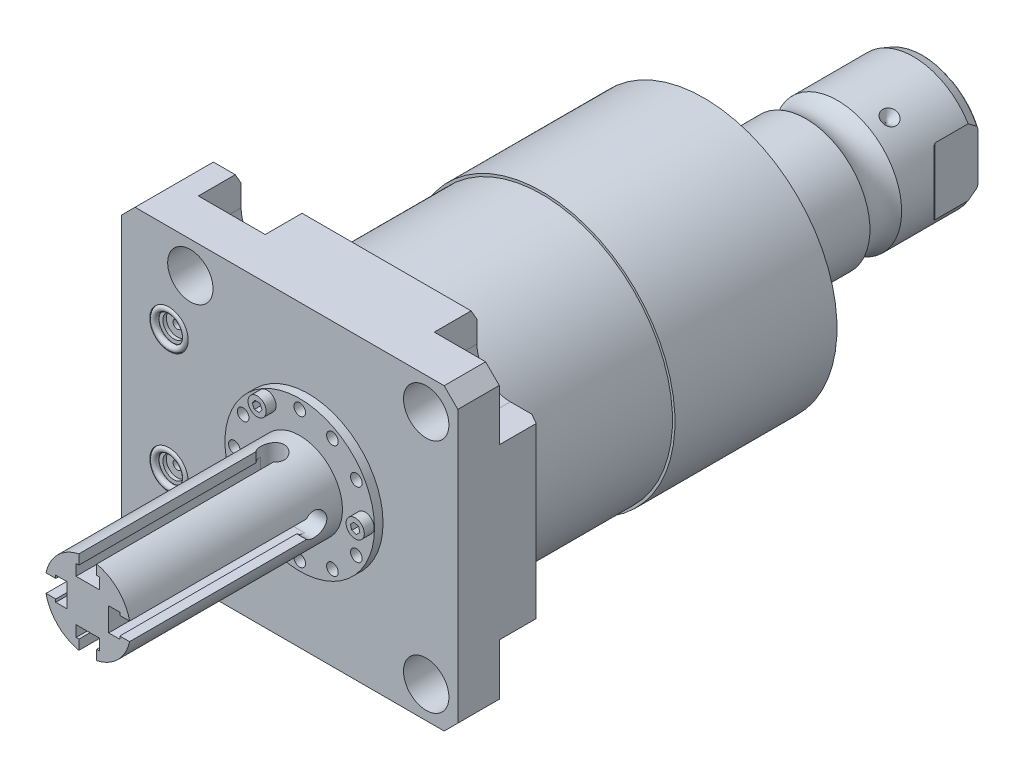
from build123d import *

# Parameters (mm, degrees)
SKETCH1_W                   = 99.9998
SKETCH1_H                   = 88.9
EXTRUDE1_DEPTH              = 25.019
SKETCH2_R                   = 6.7437
CUT_EXTRUDE1_DEPTH          = 27.5209
LPATTERN1_COUNT             = 2
LPATTERN1_PITCH             = 70.104
LPATTERN1_COUNT_DIR2        = 2
LPATTERN1_PITCH_DIR2        = 70.104
CUT_EXTRUDE2_DEPTH          = 12.7
SKETCH6_R                   = 5.7023
CUT_EXTRUDE3_DEPTH          = 1.4478
SKETCH7_R                   = 3.2512
CUT_EXTRUDE4_DEPTH          = 1.016
SKETCH8_R                   = 1.2446
CUT_EXTRUDE5_DEPTH          = 11.9888
SKETCH9_R                   = 0.9271
LPATTERN3_COUNT             = 2
LPATTERN3_PITCH             = 36.2204
CHAMFER1_SIZE               = 4.064
CHAMFER2_SIZE               = 3.0226
CHAMFER2_SIZE2              = 1.745098924
SKETCH14_R                  = 39.5224
EXTRUDE2_DEPTH              = 96.393
SKETCH15_OUTSIDE_W          = 138.19
SKETCH15_OUTSIDE_H          = 127.09
SKETCH15_OUTSIDE_R          = 38.7858
CUT_EXTRUDE9_DEPTH          = 44.45
CIRPATTERN1_COUNT           = 3
FILLET1_R                   = 0.635
CUT_EXTRUDE12_DEPTH         = 45.45
CUT_EXTRUDE12_DEPTH_BACK    = 45.45
SKETCH28_R                  = 1.7272
CUT_EXTRUDE13_DEPTH         = 2.54
SKETCH29_R                  = 2.7051
EXTRUDE3_DEPTH              = 2.9464
CUT_EXTRUDE14_DEPTH         = 2.032
CUT_EXTRUDE15_DEPTH         = 6.477
SKETCH32_W                  = 6.985
SKETCH32_H                  = 54.864
CUT_EXTRUDE16_DEPTH         = 3.302
CIRPATTERN2_COUNT           = 2
CIRPATTERN2_ANGLE           = 90
CIRPATTERN2_COPY_1_DEPTH    = 6.477
CIRPATTERN2_COPY_2_SKETCH_W = 6.985
CIRPATTERN2_COPY_2_SKETCH_H = 54.864
CIRPATTERN2_COPY_2_DEPTH    = 3.302


with BuildPart() as part:
    # Sketch1 → Extrude1 (new body)
    with BuildSketch(Plane.XY):
        with Locations((-5.5499, 0)):
            Rectangle(SKETCH1_W, SKETCH1_H)
    extrude(amount=EXTRUDE1_DEPTH)

    # Sketch2 → Cut-Extrude1 (cut)
    with BuildSketch(Plane(origin=(0, 0, 0), x_dir=(-1, 0, 0), z_dir=(0, 0, -1))):
        with Locations((-35.052, -35.052)):
            Circle(SKETCH2_R)
    cut_extrude1 = extrude(amount=-CUT_EXTRUDE1_DEPTH, mode=Mode.SUBTRACT)

    # LPattern1: Cut-Extrude1 2 × 2
    with Locations(*[(-j * LPATTERN1_PITCH_DIR2, i * LPATTERN1_PITCH, 0) for i in range(LPATTERN1_COUNT) for j in range(LPATTERN1_COUNT_DIR2) if (i, j) != (0, 0)]):
        add(cut_extrude1, mode=Mode.SUBTRACT)

    # Sketch3 → Cut-Extrude2 (cut)
    with BuildSketch(Plane(origin=(0, 0, 0), x_dir=(-1, 0, 0), z_dir=(0, 0, -1))):
        with BuildLine():
            Line((-35.052, -25.1206), (-44.45, -25.1206))
            Line((-44.45, -25.1206), (-44.45, -44.45))
            Line((-44.45, -44.45), (-25.1206, -44.45))
            Line((-25.1206, -44.45), (-25.1206, -35.052))
            ThreePointArc((-25.1206, -35.052), (-28.029439713, -28.029439713), (-35.052, -25.1206))
        make_face()
        with BuildLine():
            Line((-44.45, 25.1206), (-44.45, 44.45))
            Line((-44.45, 44.45), (-25.1206, 44.45))
            Line((-25.1206, 44.45), (-25.1206, 35.052))
            ThreePointArc((-25.1206, 35.052), (-28.029439713, 28.029439713), (-35.052, 25.1206))
            Line((-35.052, 25.1206), (-44.45, 25.1206))
        make_face()
        with BuildLine():
            Line((25.1206, 44.45), (25.1206, 35.052))
            ThreePointArc((25.1206, 35.052), (35.052, 25.1206), (44.9834, 35.052))
            Line((44.9834, 35.052), (44.9834, 44.45))
            Line((44.9834, 44.45), (25.1206, 44.45))
        make_face()
        with BuildLine():
            Line((44.9834, -44.45), (25.1206, -44.45))
            Line((25.1206, -44.45), (25.1206, -35.052))
            ThreePointArc((25.1206, -35.052), (35.052, -25.1206), (44.9834, -35.052))
            Line((44.9834, -35.052), (44.9834, -44.45))
        make_face()
    extrude(amount=-CUT_EXTRUDE2_DEPTH, mode=Mode.SUBTRACT)

    # S2D0007 → Cut-Revolve1 (revolve, cut)
    with BuildSketch(Plane(origin=(-55.5498, -13.0048, 12.0142), x_dir=(0, 1, 0), z_dir=(0, 0, 1)), mode=Mode.PRIVATE) as cut_revolve1_sk:
        Polygon((0, 0), (10.4775, 0), (10.4775, -0.254), (6.1849, -0.254), (5.642306865, -2.8067), (4.9784, -3.470606865), (4.9784, -14.224), (0, -14.224), align=None)
    revolve(cut_revolve1_sk.sketch.rotate(Axis((-40.6146, -13.0048, 12.0142), (-1, 0, 0)), 90), axis=Axis((-40.6146, -13.0048, 12.0142), (-1, 0, 0)), mode=Mode.SUBTRACT)  # turned: the seam where the file's is

    # Sketch5 → Cut-Revolve2 (revolve, cut)
    with BuildSketch(Plane(origin=(-55.5498, 13.0048, 12.0142), x_dir=(0, 1, 0), z_dir=(0, 0, 1)), mode=Mode.PRIVATE) as cut_revolve2_sk:
        Polygon((0, 0), (10.4775, 0), (10.4775, -0.254), (6.1849, -0.254), (5.642306865, -2.8067), (4.9784, -3.470606865), (4.9784, -14.224), (0, -14.224), align=None)
    revolve(cut_revolve2_sk.sketch.rotate(Axis((-40.6146, 13.0048, 12.0142), (-1, 0, 0)), 90), axis=Axis((-40.6146, 13.0048, 12.0142), (-1, 0, 0)), mode=Mode.SUBTRACT)  # turned: the seam where the file's is

    # Sketch6 → Cut-Extrude3 (cut)
    with BuildSketch(Plane.XY.offset(25.019)):
        with Locations((-41.402, -18.1102)):
            Circle(SKETCH6_R)
        with Locations((-41.402, 18.1102)):
            Circle(SKETCH6_R)
    extrude(amount=-CUT_EXTRUDE3_DEPTH, mode=Mode.SUBTRACT)

    # Sketch7 → Cut-Extrude4 (cut)
    with BuildSketch(Plane.XY.offset(23.5712)):
        with Locations((-41.402, 18.1102)):
            Circle(SKETCH7_R)
        with Locations((-41.402, -18.1102)):
            Circle(SKETCH7_R)
    extrude(amount=-CUT_EXTRUDE4_DEPTH, mode=Mode.SUBTRACT)

    # Sketch8 → Cut-Extrude5 (cut)
    with BuildSketch(Plane.XY.offset(22.5552)):
        with Locations((-41.402, 18.1102)):
            Circle(SKETCH8_R)
        with Locations((-41.402, -18.1102)):
            Circle(SKETCH8_R)
    extrude(amount=-CUT_EXTRUDE5_DEPTH, mode=Mode.SUBTRACT)

    # Chamfer1
    chamfer1_edges = [part.edges().sort_by_distance(p)[0] for p in [
        (-55.5498, 44.45, 12.5095),
        (44.45, 44.45, 18.8595),
        (44.45, -44.45, 18.8595),
        (-55.5498, -44.45, 12.5095),
    ]]
    chamfer(chamfer1_edges, length=CHAMFER1_SIZE)

    # Chamfer2
    chamfer2_edges = [part.edges().sort_by_distance(p)[0] for p in [
        (-48.2346, -44.45, 0),
        (44.45, 0, 0),
        (0, 44.45, 0),
        (-48.2346, 44.45, 0),
        (0, -44.45, 0),
    ]]
    chamfer2_side = [part.faces().sort_by_distance(p)[0] for p in [
        (-6.590443221, 0, 0),
    ]]
    chamfer(chamfer2_edges, length=CHAMFER2_SIZE, length2=CHAMFER2_SIZE2, reference=chamfer2_side[0])

    # Sketch14 → Extrude2 (add)
    with BuildSketch(Plane(origin=(0, 0, 0), x_dir=(-1, 0, 0), z_dir=(0, 0, -1))):
        Circle(SKETCH14_R)
    extrude(amount=EXTRUDE2_DEPTH)

    # Sketch15 outside → Cut-Extrude9 (cut)
    with BuildSketch(Plane(origin=(0, 0, 0), x_dir=(-1, 0, 0), z_dir=(0, 0, -1))):
        with Locations((5.55, 0)):
            Rectangle(SKETCH15_OUTSIDE_W, SKETCH15_OUTSIDE_H)
        Circle(SKETCH15_OUTSIDE_R, mode=Mode.SUBTRACT)
    extrude(amount=CUT_EXTRUDE9_DEPTH, mode=Mode.SUBTRACT)

    # Sketch16 → Cut-Revolve3 (revolve, cut)
    with BuildSketch(Plane(origin=(0, 0, 0), x_dir=(0, 0, 1), z_dir=(1, 0, 0)), mode=Mode.PRIVATE) as cut_revolve3_sk:
        Polygon((-96.393, 25.4), (-92.608914325, 39.5224), (-96.393, 39.5224), align=None)
    revolve(cut_revolve3_sk.sketch.rotate(Axis((0, 0, -96.582204284), (0, 0, 1)), 270), axis=Axis((0, 0, -96.582204284), (0, 0, 1)), mode=Mode.SUBTRACT)  # turned: the seam where the file's is

    # Sketch17 → Revolve3 (revolve)
    with BuildSketch(Plane(origin=(0, 0, 0), x_dir=(0, 0, 1), z_dir=(1, 0, 0)), mode=Mode.PRIVATE) as revolve3_sk:
        with BuildLine():
            Line((-96.393, 0), (-96.393, 19.05))
            Line((-96.393, 19.05), (-122.87710643, 19.05))
            ThreePointArc((-122.87710643, 19.05), (-127.5842, 17.5006), (-132.29129357, 19.05))
            Line((-132.29129357, 19.05), (-154.8384, 19.05))
            Line((-154.8384, 19.05), (-157.7594, 17.986842946))
            Line((-157.7594, 17.986842946), (-157.7594, 0))
            Line((-157.7594, 0), (-96.393, 0))
        make_face()
    revolve(revolve3_sk.sketch.rotate(Axis((0, 0, -180.9369), (0, 0, 1)), 270), axis=Axis((0, 0, -180.9369), (0, 0, 1)))  # turned: the seam where the file's is

    # Sketch22 → Cut-Revolve4 (revolve, cut)
    with BuildSketch(Plane(origin=(0, 0, 0), x_dir=(1, 0, 0), z_dir=(0, 1, 0)), mode=Mode.PRIVATE) as cut_revolve4_sk:
        Polygon((-19.05, 140.6652), (-16.637, 138.2522), (-19.05, 138.2522), align=None)
    cut_revolve4 = revolve(cut_revolve4_sk.sketch.rotate(Axis((-42.100308337, 0, -138.2522), (1, 0, 0)), 180), axis=Axis((-42.100308337, 0, -138.2522), (1, 0, 0)), mode=Mode.SUBTRACT)  # turned: the seam where the file's is

    # CirPattern1: Cut-Revolve4 ×3 about axis
    cirpattern1_axis = Axis((0, 0, -180.9369), (0, 0, -1))
    for i in range(1, CIRPATTERN1_COUNT):
        add(cut_revolve4.rotate(cirpattern1_axis, i * 360 / CIRPATTERN1_COUNT), mode=Mode.SUBTRACT)

    # Fillet1
    fillet1_edges = [part.edges().sort_by_distance(p)[0] for p in [
        (17.986842946, 0, -157.7594),
    ]]
    fillet(fillet1_edges, radius=FILLET1_R)

    # Sketch24 → Hole1 (revolve, cut)
    with BuildSketch(Plane(origin=(0, 0, -157.7594), x_dir=(0, 1, 0), z_dir=(1, 0, 0))):
        Polygon((0, 0), (0, 25.399999974), (6.9342, 21.23351227), (6.9342, 0), align=None)
    revolve(axis=Axis((0, 0, -162.003599587), (0, 0, 1)), mode=Mode.SUBTRACT)

    # Sketch26 → Cut-Extrude12 (cut, two sides)
    with BuildSketch(Plane(origin=(0, 0, 0), x_dir=(1, 0, 0), z_dir=(0, 1, 0))) as cut_extrude12_sk:
        with BuildLine():
            Line((-16.2814, 157.7594), (-16.2814, 145.0594))
            ThreePointArc((-16.2814, 145.0594), (-16.339403796, 144.767795225), (-16.504584633, 144.520584633))
            Line((-16.504584633, 144.520584633), (-19.05, 141.975169265))
            Line((-19.05, 141.975169265), (-19.05, 157.7594))
            Line((-19.05, 157.7594), (-16.2814, 157.7594))
        make_face()
        with BuildLine():
            Line((19.05, 157.7594), (16.2814, 157.7594))
            Line((16.2814, 157.7594), (16.2814, 145.0594))
            ThreePointArc((16.2814, 145.0594), (16.339403796, 144.767795225), (16.504584633, 144.520584633))
            Line((16.504584633, 144.520584633), (19.05, 141.975169265))
            Line((19.05, 141.975169265), (19.05, 157.7594))
        make_face()
    extrude(amount=CUT_EXTRUDE12_DEPTH, mode=Mode.SUBTRACT)
    extrude(cut_extrude12_sk.sketch, amount=-CUT_EXTRUDE12_DEPTH_BACK, mode=Mode.SUBTRACT)

    # Sketch27 → Revolve4 (revolve)
    with BuildSketch(Plane(origin=(0, 0, 0), x_dir=(1, 0, 0), z_dir=(0, 1, 0)), mode=Mode.PRIVATE) as revolve4_sk:
        Polygon((0, -25.019), (22.225, -25.019), (22.225, -27.559), (12.7, -27.559), (12.7, -90.551), (0, -90.551), align=None)
    revolve(revolve4_sk.sketch.rotate(Axis((0, 0, 994.645251724), (0, 0, -1)), 180), axis=Axis((0, 0, 994.645251724), (0, 0, -1)))  # turned: the seam where the file's is

    # Sketch28 → Cut-Extrude13 (cut)
    with BuildSketch(Plane.XY.offset(27.559)):
        with Locations((19.431, 0)):
            Circle(SKETCH28_R)
        with Locations((16.827739621, 9.7155)):
            Circle(SKETCH28_R)
        with Locations((9.7155, 16.827739621)):
            Circle(SKETCH28_R)
        with Locations((0, 19.431)):
            Circle(SKETCH28_R)
        with Locations(Location((-9.7155, 16.827739621, 0), (0, 0, 180))):  # turned: the seam where the file's is
            Circle(SKETCH28_R)
        with Locations(Location((-16.827739621, 9.7155, 0), (0, 0, 180))):  # turned: the seam where the file's is
            Circle(SKETCH28_R)
        with Locations(Location((-19.431, 0, 0), (0, 0, 180))):  # turned: the seam where the file's is
            Circle(SKETCH28_R)
        with Locations(Location((16.827739621, -9.7155, 0), (0, 0, 180))):  # turned: the seam where the file's is
            Circle(SKETCH28_R)
        with Locations(Location((9.7155, -16.827739621, 0), (0, 0, 180))):  # turned: the seam where the file's is
            Circle(SKETCH28_R)
        with Locations(Location((0, -19.431, 0), (0, 0, 180))):  # turned: the seam where the file's is
            Circle(SKETCH28_R)
        with Locations((-9.7155, -16.827739621)):
            Circle(SKETCH28_R)
        with Locations((-16.827739621, -9.7155)):
            Circle(SKETCH28_R)
    extrude(amount=-CUT_EXTRUDE13_DEPTH, mode=Mode.SUBTRACT)

    # Sketch29 → Extrude3 (add)
    with BuildSketch(Plane.XY.offset(27.559)):
        with Locations((19.431, 0)):
            Circle(SKETCH29_R)
        with Locations((-9.7155, 16.827739621)):
            Circle(SKETCH29_R)
        with Locations((-9.7155, -16.827739621)):
            Circle(SKETCH29_R)
    extrude(amount=EXTRUDE3_DEPTH)

    # Sketch30 → Cut-Extrude14 (cut)
    with BuildSketch(Plane.XY.offset(30.5054)):
        Polygon((19.802173147, -1.388381327), (20.818960073, -0.372745288), (20.447786925, 1.015636038), (19.059826853, 1.388381327), (18.043039927, 0.372745288), (18.414213075, -1.015636038), align=None)
        Polygon((-9.086136589, 15.535735786), (-8.281910151, 16.726782406), (-8.911273563, 18.018786241), (-10.344863411, 18.119743456), (-11.149089849, 16.928696836), (-10.519726437, 15.636693001), align=None)
        Polygon((-9.022139215, -18.086557731), (-8.278651145, -16.856680622), (-8.97201193, -15.597862512), (-10.408860785, -15.56892151), (-11.152348855, -16.798798619), (-10.45898807, -18.05761673), align=None)
    extrude(amount=-CUT_EXTRUDE14_DEPTH, mode=Mode.SUBTRACT)

    # Sketch31 → Cut-Extrude15 (cut)
    with BuildSketch(Plane(origin=(0, 12.7, 59.055), x_dir=(-1, 0, 0), z_dir=(0, 1, 0))):
        with BuildLine():
            Line((-2.6416, 31.496), (-2.6416, -21.083376248))
            ThreePointArc((-2.6416, -21.083376248), (0, -26.8605), (2.6416, -21.083376248))
            Line((2.6416, -21.083376248), (2.6416, 31.496))
            Line((2.6416, 31.496), (-2.6416, 31.496))
        make_face()
    cut_extrude15 = extrude(amount=-CUT_EXTRUDE15_DEPTH, mode=Mode.SUBTRACT)

    # Sketch32 → Cut-Extrude16 (cut)
    with BuildSketch(Plane(origin=(0, 6.223, 0), x_dir=(1, 0, 0), z_dir=(0, 1, 0))):
        with Locations((0, -63.119)):
            Rectangle(SKETCH32_W, SKETCH32_H)
    cut_extrude16 = extrude(amount=CUT_EXTRUDE16_DEPTH, mode=Mode.SUBTRACT)

    # Mirror1: Cut-Extrude15, Cut-Extrude16 across plane
    add(cut_extrude15.mirror(Plane.ZX), mode=Mode.SUBTRACT)
    add(cut_extrude16.mirror(Plane.ZX), mode=Mode.SUBTRACT)

    # CirPattern2: Cut-Extrude15, Cut-Extrude16 ×2 about axis
    cirpattern2_axis = Axis((0, 0, 0), (0, 0, 1))
    add([cut_extrude15.rotate(cirpattern2_axis, i * CIRPATTERN2_ANGLE / (CIRPATTERN2_COUNT - 1)) for i in range(1, CIRPATTERN2_COUNT)], mode=Mode.SUBTRACT)
    add([cut_extrude16.rotate(cirpattern2_axis, i * CIRPATTERN2_ANGLE / (CIRPATTERN2_COUNT - 1)) for i in range(1, CIRPATTERN2_COUNT)], mode=Mode.SUBTRACT)

    # CirPattern2 copy 1 sketch → CirPattern2 copy 1 (cut)
    with BuildSketch(Plane(origin=(12.7, 0, 59.055), x_dir=(0, -1, 0), z_dir=(1, 0, 0))):
        with BuildLine():
            Line((-2.6416, -31.496), (-2.6416, 21.083376248))
            ThreePointArc((-2.6416, 21.083376248), (0, 26.8605), (2.6416, 21.083376248))
            Line((2.6416, 21.083376248), (2.6416, -31.496))
            Line((2.6416, -31.496), (-2.6416, -31.496))
        make_face()
    extrude(amount=-CIRPATTERN2_COPY_1_DEPTH, mode=Mode.SUBTRACT)

    # CirPattern2 copy 2 sketch → CirPattern2 copy 2 (cut)
    with BuildSketch(Plane.YZ.offset(6.223)):
        with Locations((0, 63.119)):
            Rectangle(CIRPATTERN2_COPY_2_SKETCH_W, CIRPATTERN2_COPY_2_SKETCH_H)
    extrude(amount=CIRPATTERN2_COPY_2_DEPTH, mode=Mode.SUBTRACT)


with BuildPart() as body_2:
    # Sketch9 → Revolve1 (revolve)
    with BuildSketch(Plane(origin=(-41.656, 18.1102, 23.5712), x_dir=(1, 0, 0), z_dir=(0, 1, 0))):
        with Locations((5.0292, -0.9271)):
            Circle(SKETCH9_R)
    revolve(axis=Axis((-41.402, 18.1102, 25.51811), (0, 0, -1)))


with BuildPart() as lpattern3_1:
    # LPattern3: pattern copy
    add(body_2.part.moved(Location(Vector(0, -1, 0) * (1 * LPATTERN3_PITCH))))


solid = Compound([part.part, body_2.part, lpattern3_1.part])
